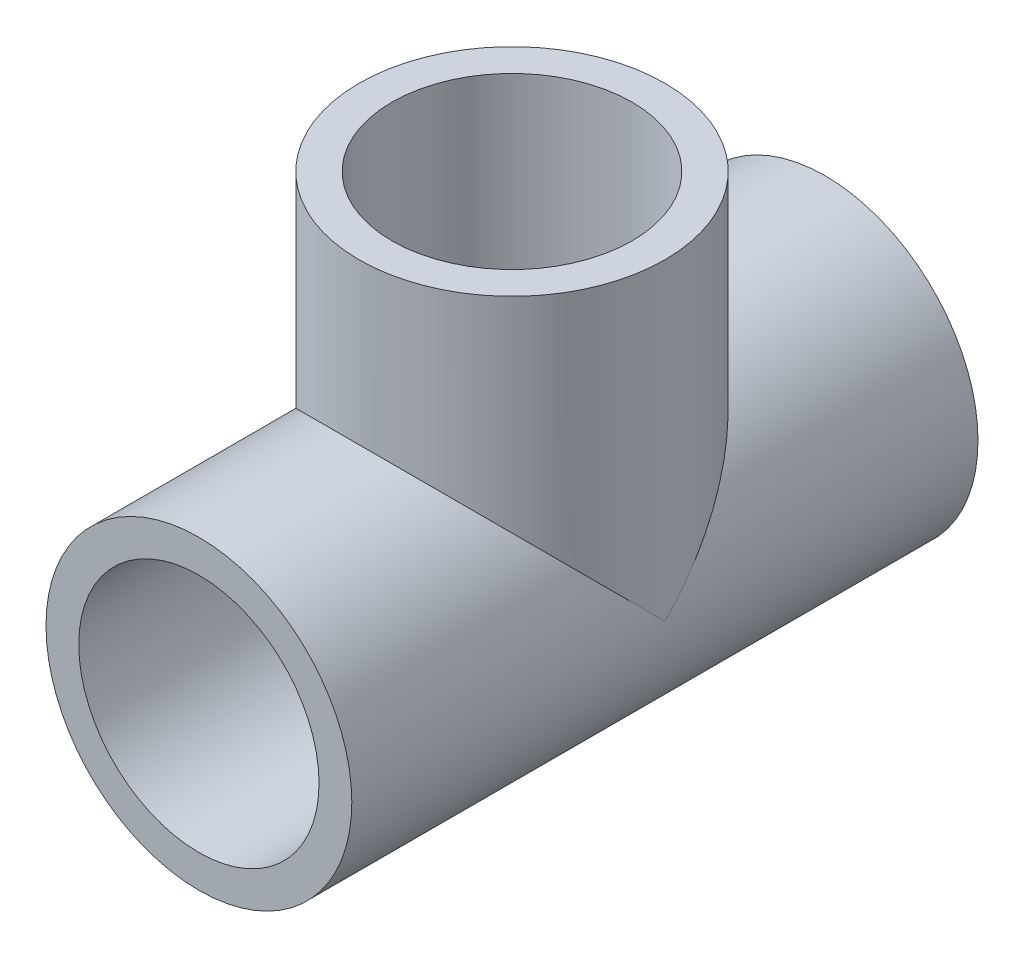
from build123d import *

# Parameters (mm, degrees)
SKETCH1_W          = 16.66875
SKETCH1_H          = 68.2625
SKETCH2_W          = 16.66875
SKETCH2_H          = 34.13125
SKETCH7_R          = 12.7
CUT_EXTRUDE1_DEPTH = 69.2625
CUT_EXTRUDE2_REACH = 52.8
SKETCH8_R          = 12.7
SKETCH9_R          = 13.096875
CUT_EXTRUDE3_DEPTH = 19.05
SKETCH10_R         = 13.096875
CUT_EXTRUDE4_DEPTH = 19.05
SKETCH11_R         = 13.096875
CUT_EXTRUDE5_DEPTH = 19.05


with BuildPart() as part:
    # Sketch1 → Revolve1 (revolve)
    with BuildSketch(Plane(origin=(0, 0, 0), x_dir=(1, 0, 0), z_dir=(0, 1, 0))):
        with Locations((8.334375, 0)):
            Rectangle(SKETCH1_W, SKETCH1_H)
    revolve(axis=Axis((0, 0, 118.243982537), (0, 0, -1)))

    # Sketch2 → Revolve2 (revolve)
    with BuildSketch(Plane.XY):
        with Locations((-8.334375, 17.065625)):
            Rectangle(SKETCH2_W, SKETCH2_H)
    revolve(axis=Axis((0, 0, 0), (0, 1, 0)))

    # Sketch7 → Cut-Extrude1 (cut, through all)
    with BuildSketch(Plane.XY.offset(34.13125)):
        Circle(SKETCH7_R)
    extrude(amount=-CUT_EXTRUDE1_DEPTH, mode=Mode.SUBTRACT)

    # Sketch8 → Cut-Extrude2 (cut, up to next)
    with BuildSketch(Plane(origin=(0, 34.13125, 0), x_dir=(1, 0, 0), z_dir=(0, 1, 0)), mode=Mode.PRIVATE) as cut_extrude2_sk1:
        Circle(SKETCH8_R)
    cut_extrude2_tool1 = extrude(cut_extrude2_sk1.sketch, amount=-CUT_EXTRUDE2_REACH, mode=Mode.PRIVATE) & part.part
    add(cut_extrude2_tool1.solids().sort_by_distance((0, 34.13125, 0))[0], mode=Mode.SUBTRACT)

    # Sketch9 → Cut-Extrude3 (cut)
    with BuildSketch(Plane.XY.offset(34.13125)):
        Circle(SKETCH9_R)
    extrude(amount=-CUT_EXTRUDE3_DEPTH, mode=Mode.SUBTRACT)

    # Sketch10 → Cut-Extrude4 (cut)
    with BuildSketch(Plane(origin=(0, 0, -34.13125), x_dir=(-1, 0, 0), z_dir=(0, 0, -1))):
        Circle(SKETCH10_R)
    extrude(amount=-CUT_EXTRUDE4_DEPTH, mode=Mode.SUBTRACT)

    # Sketch11 → Cut-Extrude5 (cut)
    with BuildSketch(Plane(origin=(0, 34.13125, 0), x_dir=(1, 0, 0), z_dir=(0, 1, 0))):
        Circle(SKETCH11_R)
    extrude(amount=-CUT_EXTRUDE5_DEPTH, mode=Mode.SUBTRACT)


solid = part.part
